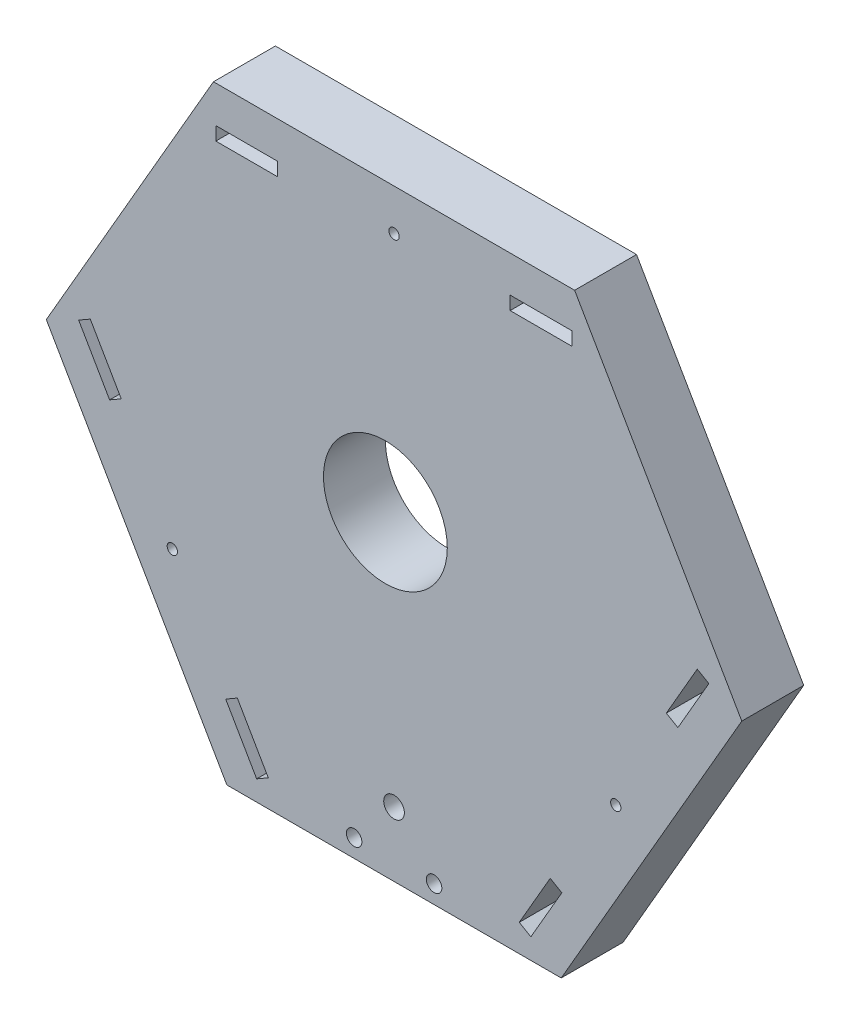
from build123d import *

# Parameters (mm, degrees)
ESBO_O1_R                = 2
ESBO_O1_R_2              = 1.5
ESBO_O1_R_3              = 1
ESBO_O1_R_4              = 12
ESBO_O1_W                = 12
ESBO_O1_H                = 2.6
RESSALTO_EXTRUS_O1_DEPTH = 12


with BuildPart() as part:
    # Esboço1 → Ressalto-extrusão1 (new body)
    with BuildSketch(Plane.XY):
        Polygon((312.401923789, 240.878221735), (347.401923789, 301.5), (315, 357.621778265), (245, 357.621778265), (212.598076211, 301.5), (247.598076211, 240.878221735), align=None)
        with Locations((280, 253.378221735)):
            Circle(ESBO_O1_R, mode=Mode.SUBTRACT)
        with Locations((272.260343171, 244.388972359)):
            Circle(ESBO_O1_R_2, mode=Mode.SUBTRACT)
        with Locations((287.760343171, 244.388972359)):
            Circle(ESBO_O1_R_2, mode=Mode.SUBTRACT)
        with Locations((280, 349.621778265)):
            Circle(ESBO_O1_R_3, mode=Mode.SUBTRACT)
        with Locations((237.026279442, 275.189110868)):
            Circle(ESBO_O1_R_3, mode=Mode.SUBTRACT)
        with Locations((322.973720558, 275.189110868)):
            Circle(ESBO_O1_R_3, mode=Mode.SUBTRACT)
        with Locations((278.32399049, 302.032244112)):
            Circle(ESBO_O1_R_4, mode=Mode.SUBTRACT)
        with Locations((251.453146627, 349.186651246)):
            Rectangle(ESBO_O1_W, ESBO_O1_H, mode=Mode.SUBTRACT)
        with Locations((308.5, 349.259600438)):
            Rectangle(ESBO_O1_W, ESBO_O1_H, mode=Mode.SUBTRACT)
        Polygon((332.76851184, 295.516364843), (335.020177889, 294.216364843), (341.020177889, 304.608669688), (338.76851184, 305.908669688), align=None, mode=Mode.SUBTRACT)
        Polygon((310.272092192, 256.543153732), (312.523758242, 255.243153732), (306.520177889, 244.852916827), (304.26851184, 246.152916827), align=None, mode=Mode.SUBTRACT)
        Polygon((255.623234985, 246.090416827), (253.371568935, 244.790416827), (247.371568935, 255.182721672), (249.623234985, 256.482721672), align=None, mode=Mode.SUBTRACT)
        Polygon((227.123234985, 295.453864843), (224.871568935, 294.153864843), (218.871568935, 304.546169688), (221.123234985, 305.846169688), align=None, mode=Mode.SUBTRACT)
    extrude(amount=RESSALTO_EXTRUS_O1_DEPTH)


solid = part.part
